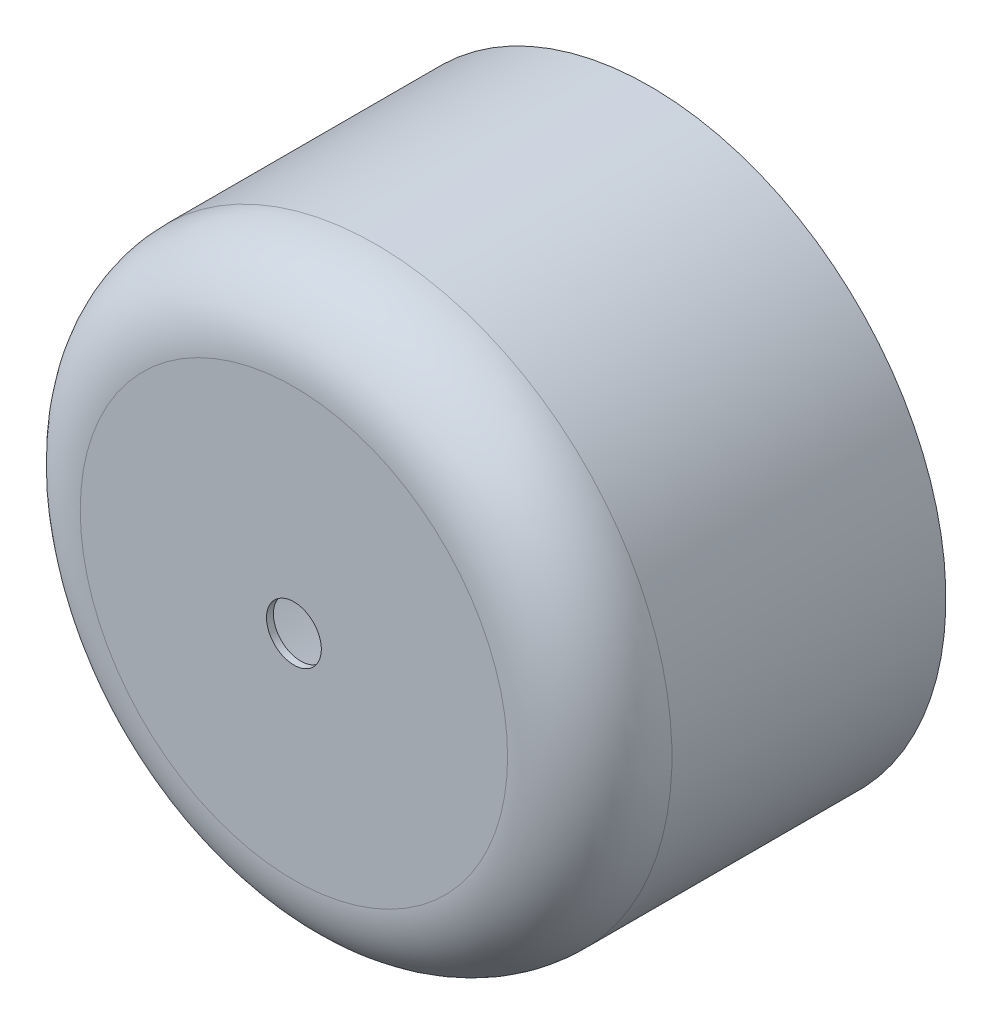
from build123d import *


with BuildPart() as part:
    # Schizzo1 → Rivoluzione1 (revolve)
    with BuildSketch(Plane.XZ):
        with BuildLine():
            Line((10.8, 0), (10.8, 10))
            ThreePointArc((10.8, 10), (9.921320344, 12.121320344), (7.8, 13))
            Line((7.8, 13), (1, 13))
            Line((1, 13), (1, 12.75))
            Line((1, 12.75), (7.8, 12.75))
            ThreePointArc((7.8, 12.75), (9.744543648, 11.944543648), (10.55, 10))
            Line((10.55, 10), (10.55, 0))
            Line((10.55, 0), (10.8, 0))
        make_face()
    revolve(axis=Axis((0, 0, 13), (0, 0, -1)))


solid = part.part
